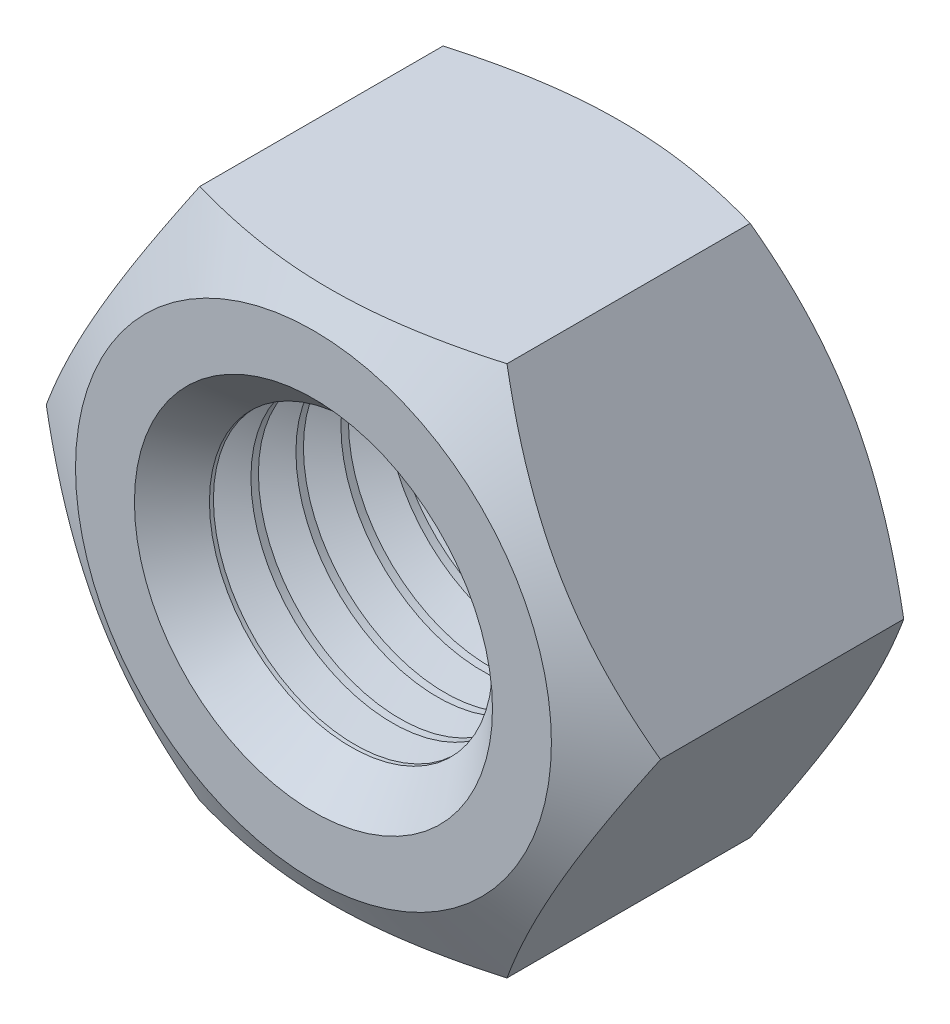
from build123d import *

# Parameters (mm, degrees)
SKETCH1_R        = 3.4585
BASENUT_DEPTH    = 7.5
ENDCHAMFER2_SIZE = 0.9165
LPATTERN10_COUNT = 6
LPATTERN10_PITCH = 1.0998


with BuildPart() as part:
    # Sketch1 → BaseNut (new body)
    with BuildSketch(Plane.XY):
        Polygon((3.75277675, -6.5), (7.505553499, 0), (3.75277675, 6.5), (-3.75277675, 6.5), (-7.505553499, 0), (-3.75277675, -6.5), align=None)
        Circle(SKETCH1_R, mode=Mode.SUBTRACT)
    extrude(amount=-BASENUT_DEPTH)

    # Sketch2 → Chamfer1 (revolve, cut)
    with BuildSketch(Plane(origin=(15.04811501, 0, -16.706149795), x_dir=(0, 0, -1), z_dir=(0, 1, 0))):
        Polygon((-9.786706379, 22.553668509), (-9.206149795, 21.54811501), (-9.206149795, 22.553668509), align=None)
    revolve(axis=Axis((0, 0, 7.016501752), (0, 0, -1)), mode=Mode.SUBTRACT)

    # Sketch6 → EndChamfer1 (revolve, cut)
    with BuildSketch(Plane(origin=(-9.197458863, 0, -10.252541137), x_dir=(0, 0, 1), z_dir=(0, 1, 0))):
        Polygon((2.752541137, 12.655958863), (2.752541137, 13.572458863), (3.281682659, 12.655958863), align=None)
    revolve(axis=Axis((0, 0, 13.104863586), (0, 0, -1)), mode=Mode.SUBTRACT)

    # Sketch5 → Chamfer2 (revolve, cut)
    with BuildSketch(Plane(origin=(-14.793032735, 0, -16.96123207), x_dir=(0, 0, 1), z_dir=(0, 1, 0))):
        Polygon((16.96123207, 20.608032735), (16.96123207, 22.298586235), (15.985190552, 22.298586235), align=None)
    revolve(axis=Axis((0, 0, -39.536013381), (0, 0, 1)), mode=Mode.SUBTRACT)

    # EndChamfer2
    endchamfer2_edges = [part.edges().sort_by_distance(p)[0] for p in [
        (-3.4585, 0, 0),
    ]]
    chamfer(endchamfer2_edges, length=ENDCHAMFER2_SIZE)

    # Sketch7 → Cut-Revolve10 (revolve, cut)
    with BuildSketch(Plane(origin=(0, 0, 0), x_dir=(1, 0, 0), z_dir=(0, 1, 0))):
        Polygon((2.542, 7.429108478), (3.4585, 7.429108478), (4.252212283, 6.970858478), (3.4585, 6.512608478), (2.542, 6.512608478), align=None)
    cut_revolve10 = revolve(axis=Axis((0, 0, -48.618332322), (0, 0, 1)), mode=Mode.SUBTRACT)

    # LPattern10: Cut-Revolve10 ×6
    with Locations(*[(0, 0, i * LPATTERN10_PITCH) for i in range(1, LPATTERN10_COUNT)]):
        add(cut_revolve10, mode=Mode.SUBTRACT)


solid = part.part
